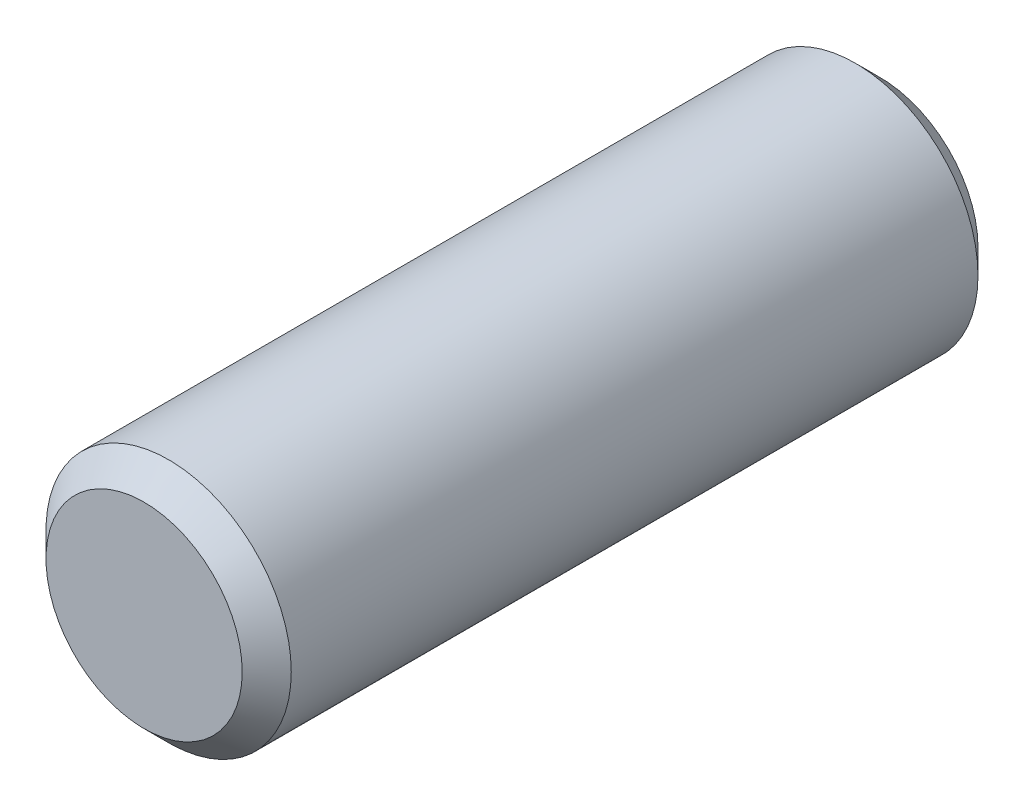
from build123d import *

# Parameters (mm, degrees)
SKETCH_1_R      = 1
EXTRUDE_1_DEPTH = 3
CHAMFER_1_SIZE  = 0.2


with BuildPart() as part:
    # 草图1 → 凸台-拉伸1 (new body, symmetric)
    with BuildSketch(Plane.XY):
        Circle(SKETCH_1_R)
    extrude(amount=EXTRUDE_1_DEPTH, both=True)

    # 倒角1
    chamfer_1_edges = [part.edges().sort_by_distance(p)[0] for p in [
        (-1, 0, -3),
        (-1, 0, 3),
    ]]
    chamfer(chamfer_1_edges, length=CHAMFER_1_SIZE)


solid = part.part
